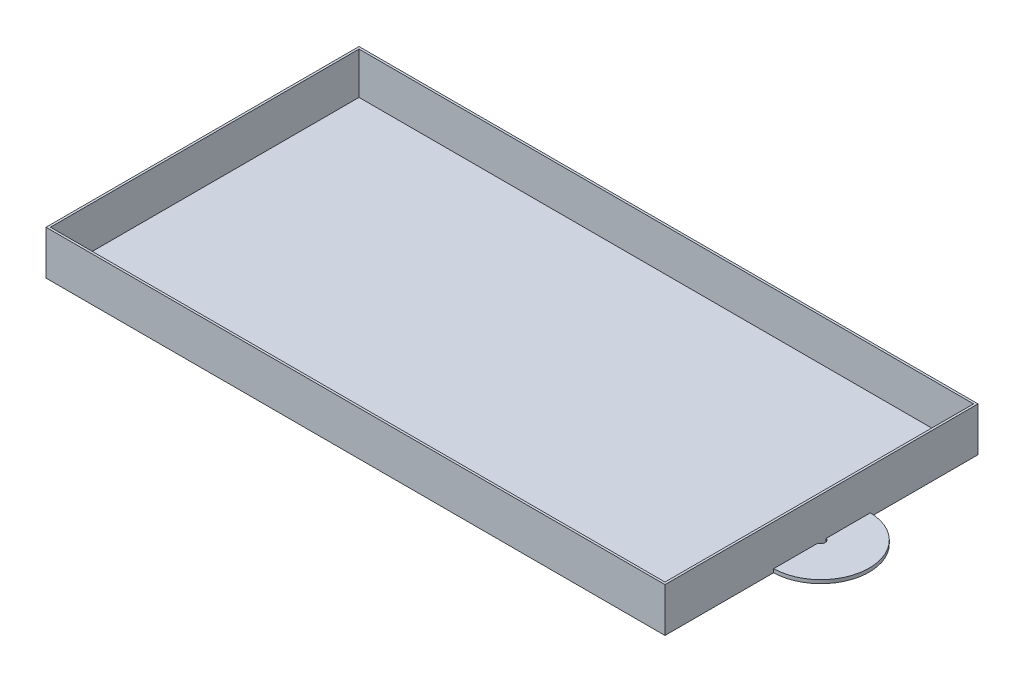
from build123d import *

# Parameters (mm, degrees)
CROQUIS1_W              = 140.396098848
CROQUIS1_H              = 71.000312846
SALIENTE_EXTRUIR1_DEPTH = 10
VACIADO1_T              = -0.5
EXTRUIR_L_MINA1_DEPTH   = 0.8


with BuildPart() as part:
    # Croquis1 → Saliente-Extruir1 (new body)
    with BuildSketch(Plane(origin=(0, 0, 0), x_dir=(1, 0, 0), z_dir=(0, 1, 0))):
        with Locations((-70.198049424, -32.892800302)):
            Rectangle(CROQUIS1_W, CROQUIS1_H)
    extrude(amount=SALIENTE_EXTRUIR1_DEPTH)

    # Vaciado1
    vaciado1_openings = [part.faces().sort_by_distance(p)[0] for p in [
        (-70.198049424, 10, 32.892800302),
    ]]
    offset(amount=VACIADO1_T, openings=vaciado1_openings, kind=Kind.INTERSECTION)

    # Croquis2 → Extruir-Lámina1 (add)
    with BuildSketch(Plane(origin=(0, 0, 0), x_dir=(1, 0, 0), z_dir=(0, 1, 0))):
        with BuildLine():
            ThreePointArc((-0.5, -21.806712241), (10.724107373, -32.530819614), (0, -43.754926987))
            Line((0, -43.754926987), (-0.227749871, -33.757520824))
            ThreePointArc((-0.227749871, -33.757520824), (0.72670121, -32.758569485), (-0.272250129, -31.804118404))
            Line((-0.272250129, -31.804118404), (-0.5, -21.806712241))
        make_face()
    extrude(amount=EXTRUIR_L_MINA1_DEPTH)


solid = part.part
